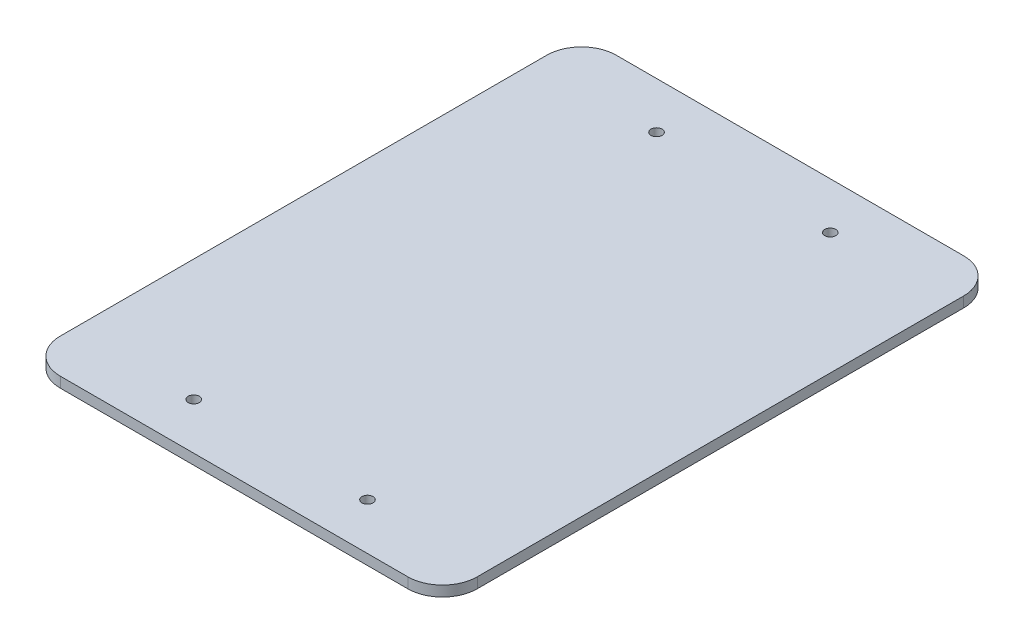
from build123d import *

# Parameters (mm, degrees)
SALIENTE_EXTRUIR1_DEPTH = 3
CROQUIS2_R              = 1.5875
CORTAR_EXTRUIR1_DEPTH   = 10


with BuildPart() as part:
    # Croquis1 → Saliente-Extruir1 (new body)
    with BuildSketch(Plane(origin=(0, 0, 0), x_dir=(1, 0, 0), z_dir=(0, 1, 0))):
        with BuildLine():
            Line((10, 0), (110, 0))
            ThreePointArc((110, 0), (117.071067812, 2.928932188), (120, 10))
            Line((120, 10), (120, 150))
            ThreePointArc((120, 150), (117.071067812, 157.071067812), (110, 160))
            Line((110, 160), (10, 160))
            ThreePointArc((10, 160), (2.928932188, 157.071067812), (0, 150))
            Line((0, 150), (0, 10))
            ThreePointArc((0, 10), (2.928932188, 2.928932188), (10, 0))
        make_face()
    extrude(amount=SALIENTE_EXTRUIR1_DEPTH)

    # Croquis2 → Cortar-Extruir1 (cut)
    with BuildSketch(Plane(origin=(0, 3, 0), x_dir=(1, 0, 0), z_dir=(0, 1, 0))):
        with Locations((35, 146.59)):
            Circle(CROQUIS2_R)
        with Locations((85, 146.59)):
            Circle(CROQUIS2_R)
        with Locations((35, 13.41)):
            Circle(CROQUIS2_R)
        with Locations((85, 13.41)):
            Circle(CROQUIS2_R)
    extrude(amount=-CORTAR_EXTRUIR1_DEPTH, mode=Mode.SUBTRACT)


solid = part.part
